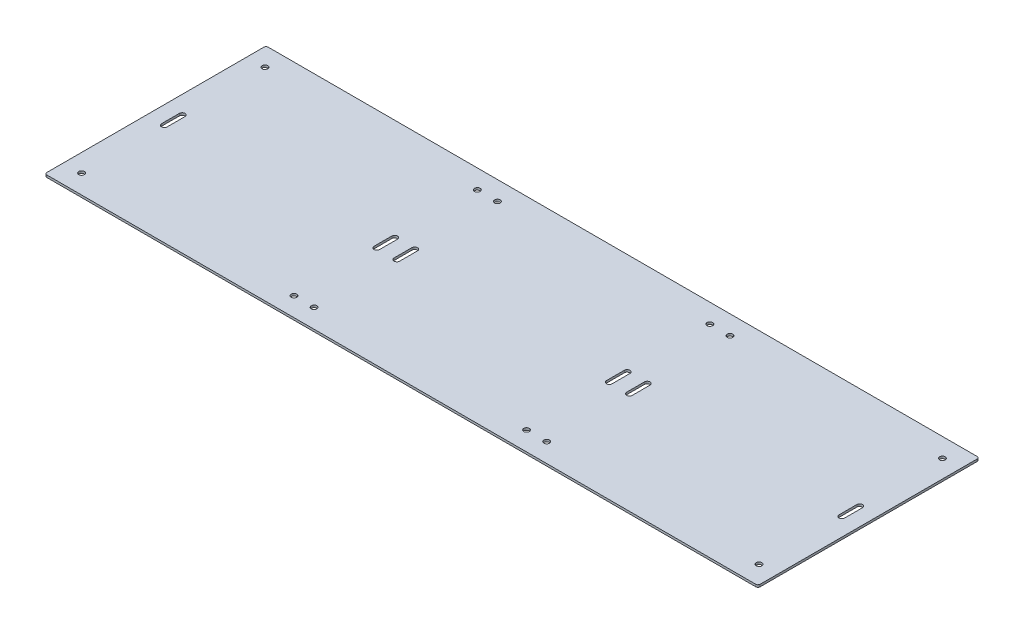
from build123d import *

# Parameters (mm, degrees)
SKETCH1_R           = 7.9375
BOSS_EXTRUDE1_DEPTH = 6.35


with BuildPart() as part:
    # Sketch1 → Boss-Extrude1 (new body)
    with BuildSketch(Plane(origin=(0, 0, 0), x_dir=(1, 0, 0), z_dir=(0, 1, 0))):
        with BuildLine():
            Line((6.35, 0), (2019.3, 0))
            ThreePointArc((2019.3, 0), (2023.790128061, 1.859871939), (2025.65, 6.35))
            Line((2025.65, 6.35), (2025.65, 622.3))
            ThreePointArc((2025.65, 622.3), (2023.790128061, 626.790128061), (2019.3, 628.65))
            Line((2019.3, 628.65), (6.35, 628.65))
            ThreePointArc((6.35, 628.65), (1.859871939, 626.790128061), (0, 622.3))
            Line((0, 622.3), (0, 6.35))
            ThreePointArc((0, 6.35), (1.859871939, 1.859871939), (6.35, 0))
        make_face()
        with Locations((50.8, 574.675)):
            Circle(SKETCH1_R, mode=Mode.SUBTRACT)
        with Locations((1974.85, 574.675)):
            Circle(SKETCH1_R, mode=Mode.SUBTRACT)
        with Locations((1974.85, 53.975)):
            Circle(SKETCH1_R, mode=Mode.SUBTRACT)
        with Locations((50.8, 53.975)):
            Circle(SKETCH1_R, mode=Mode.SUBTRACT)
        with Locations((654.05, 574.675)):
            Circle(SKETCH1_R, mode=Mode.SUBTRACT)
        with Locations((1371.6, 574.675)):
            Circle(SKETCH1_R, mode=Mode.SUBTRACT)
        with Locations((711.2, 574.675)):
            Circle(SKETCH1_R, mode=Mode.SUBTRACT)
        with Locations((711.2, 53.975)):
            Circle(SKETCH1_R, mode=Mode.SUBTRACT)
        with Locations((654.05, 53.975)):
            Circle(SKETCH1_R, mode=Mode.SUBTRACT)
        with Locations((1314.45, 574.675)):
            Circle(SKETCH1_R, mode=Mode.SUBTRACT)
        with Locations((1314.45, 53.975)):
            Circle(SKETCH1_R, mode=Mode.SUBTRACT)
        with Locations((1371.6, 53.975)):
            Circle(SKETCH1_R, mode=Mode.SUBTRACT)
        with BuildLine():
            Line((58.7375, 339.725), (58.7375, 288.925))
            ThreePointArc((58.7375, 288.925), (50.8, 280.9875), (42.8625, 288.925))
            Line((42.8625, 288.925), (42.8625, 339.725))
            ThreePointArc((42.8625, 339.725), (50.8, 347.6625), (58.7375, 339.725))
        make_face(mode=Mode.SUBTRACT)
        with BuildLine():
            Line((661.9875, 339.725), (661.9875, 288.925))
            ThreePointArc((661.9875, 288.925), (654.05, 280.9875), (646.1125, 288.925))
            Line((646.1125, 288.925), (646.1125, 339.725))
            ThreePointArc((646.1125, 339.725), (654.05, 347.6625), (661.9875, 339.725))
        make_face(mode=Mode.SUBTRACT)
        with BuildLine():
            Line((719.1375, 339.725), (719.1375, 288.925))
            ThreePointArc((719.1375, 288.925), (711.2, 280.9875), (703.2625, 288.925))
            Line((703.2625, 288.925), (703.2625, 339.725))
            ThreePointArc((703.2625, 339.725), (711.2, 347.6625), (719.1375, 339.725))
        make_face(mode=Mode.SUBTRACT)
        with BuildLine():
            Line((1966.9125, 339.725), (1966.9125, 288.925))
            ThreePointArc((1966.9125, 288.925), (1974.85, 280.9875), (1982.7875, 288.925))
            Line((1982.7875, 288.925), (1982.7875, 339.725))
            ThreePointArc((1982.7875, 339.725), (1974.85, 347.6625), (1966.9125, 339.725))
        make_face(mode=Mode.SUBTRACT)
        with BuildLine():
            Line((1306.5125, 339.725), (1306.5125, 288.925))
            ThreePointArc((1306.5125, 288.925), (1314.45, 280.9875), (1322.3875, 288.925))
            Line((1322.3875, 288.925), (1322.3875, 339.725))
            ThreePointArc((1322.3875, 339.725), (1314.45, 347.6625), (1306.5125, 339.725))
        make_face(mode=Mode.SUBTRACT)
        with BuildLine():
            Line((1363.6625, 339.725), (1363.6625, 288.925))
            ThreePointArc((1363.6625, 288.925), (1371.6, 280.9875), (1379.5375, 288.925))
            Line((1379.5375, 288.925), (1379.5375, 339.725))
            ThreePointArc((1379.5375, 339.725), (1371.6, 347.6625), (1363.6625, 339.725))
        make_face(mode=Mode.SUBTRACT)
    extrude(amount=BOSS_EXTRUDE1_DEPTH)


solid = part.part
